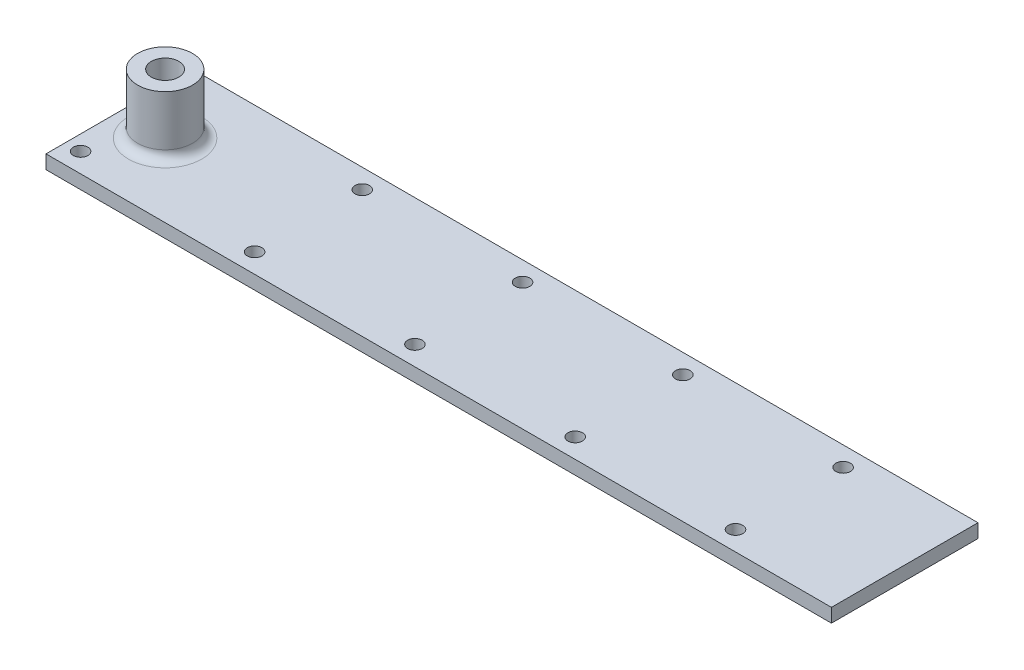
from build123d import *

# Parameters (mm, degrees)
SKETCH1_R           = 6
SKETCH1_R_2         = 3
BOSS_EXTRUDE1_DEPTH = 13
SKETCH2_W           = 171.5
SKETCH2_H           = 32
SKETCH2_R           = 1.5875
BOSS_EXTRUDE2_DEPTH = 3
CUT_EXTRUDE1_DEPTH  = 1.5


with BuildPart() as part:
    # Sketch1 → Boss-Extrude1 (new body)
    with BuildSketch(Plane(origin=(0, 0, 0), x_dir=(1, 0, 0), z_dir=(0, 1, 0))):
        Circle(SKETCH1_R)
        Circle(SKETCH1_R_2, mode=Mode.SUBTRACT)
    extrude(amount=-BOSS_EXTRUDE1_DEPTH)


with BuildPart() as body_2:
    # Sketch2 → Boss-Extrude2 (new body)
    with BuildSketch(Plane.XZ.offset(13)):
        with Locations((75.75, 0)):
            Rectangle(SKETCH2_W, SKETCH2_H)
        with Locations((136.3, -11.75)):
            Circle(SKETCH2_R, mode=Mode.SUBTRACT)
        with Locations((136.3, 11.75)):
            Circle(SKETCH2_R, mode=Mode.SUBTRACT)
        with Locations((101.3, -11.75)):
            Circle(SKETCH2_R, mode=Mode.SUBTRACT)
        with Locations((66.3, -11.75)):
            Circle(SKETCH2_R, mode=Mode.SUBTRACT)
        with Locations((31.3, -11.75)):
            Circle(SKETCH2_R, mode=Mode.SUBTRACT)
        with Locations((101.3, 11.75)):
            Circle(SKETCH2_R, mode=Mode.SUBTRACT)
        with Locations((66.3, 11.75)):
            Circle(SKETCH2_R, mode=Mode.SUBTRACT)
        with Locations((31.3, 11.75)):
            Circle(SKETCH2_R, mode=Mode.SUBTRACT)
        with Locations((-6.7, 11.75)):
            Circle(SKETCH2_R, mode=Mode.SUBTRACT)
        with Locations((-6.7, -11.75)):
            Circle(SKETCH2_R, mode=Mode.SUBTRACT)
    extrude(amount=BOSS_EXTRUDE2_DEPTH)


with BuildPart() as cut_extrude1_tool:
    # Sketch7 → Cut-Extrude1 (new, symmetric)
    with BuildSketch(Plane.ZY):
        with BuildLine():
            Line((-7.5, -16), (7.5, -16))
            Line((7.5, -16), (7.5, -15.604343213))
            ThreePointArc((7.5, -15.604343213), (7.060083625, -14.352888426), (5.933860916, -13.651969092))
            Line((5.933860916, -13.651969092), (4.566139084, -13.348030908))
            ThreePointArc((4.566139084, -13.348030908), (3.439916375, -12.647111574), (3, -11.395656787))
            Line((3, -11.395656787), (-3, -11.395656787))
            ThreePointArc((-3, -11.395656787), (-3.439916375, -12.647111574), (-4.566139084, -13.348030908))
            Line((-4.566139084, -13.348030908), (-5.933860916, -13.651969092))
            ThreePointArc((-5.933860916, -13.651969092), (-7.060083625, -14.352888426), (-7.5, -15.604343213))
            Line((-7.5, -15.604343213), (-7.5, -16))
        make_face()
    extrude(amount=CUT_EXTRUDE1_DEPTH, both=True)


with BuildPart() as part_1:
    add(part.part)

    # Cut-Extrude1: cut by cut_extrude1_tool
    add(cut_extrude1_tool.part, mode=Mode.SUBTRACT)



with BuildPart() as body_2_1:
    add(body_2.part)

    # Cut-Extrude1: cut by cut_extrude1_tool
    add(cut_extrude1_tool.part, mode=Mode.SUBTRACT)


with BuildPart() as part_2:
    add(part_1.part)

    add(body_2_1.part)  # Revolve1 merges body 2
    # Sketch8 → Revolve1 (revolve)
    with BuildSketch(Plane.ZY):
        with BuildLine():
            Line((-8, -13), (-6, -13))
            Line((-6, -13), (-6, -11))
            ThreePointArc((-6, -11), (-6.585786438, -12.414213562), (-8, -13))
        make_face()
    revolve(axis=Axis((0, 4.095579303, 0), (0, -1, 0)))


solid = part_2.part
